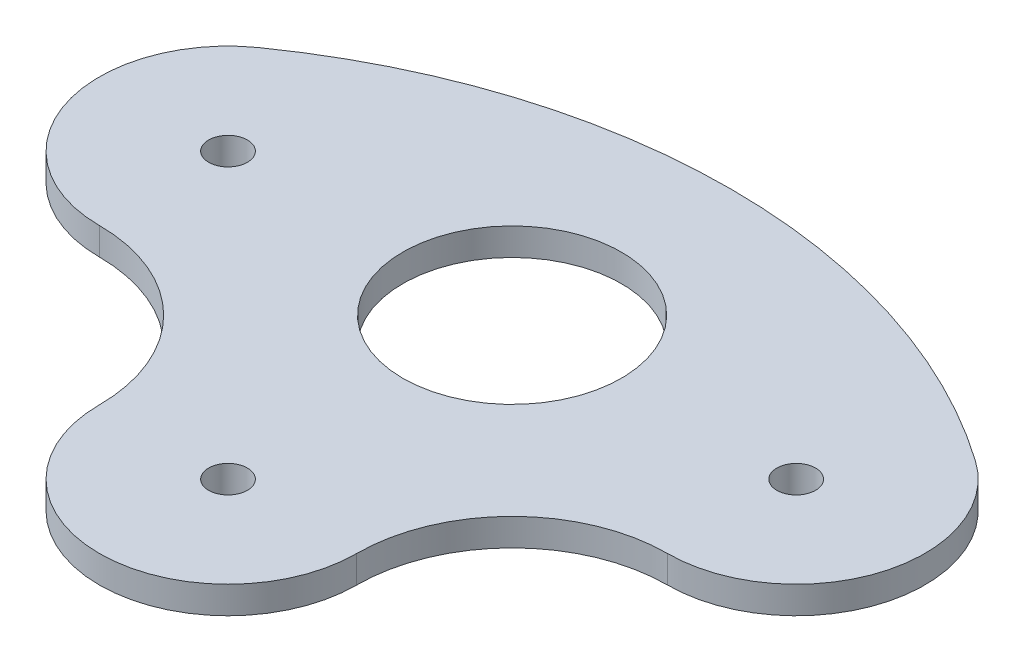
from build123d import *

# Parameters (mm, degrees)
SKETCH1_R           = 12.7
SKETCH1_R_2         = 2.25
BOSS_EXTRUDE1_DEPTH = 3.175


with BuildPart() as part:
    # Sketch1 → Boss-Extrude1 (new body)
    with BuildSketch(Plane(origin=(0, 0, 0), x_dir=(1, 0, 0), z_dir=(0, 1, 0))):
        with BuildLine():
            ThreePointArc((-41.605402676, 12.224955819), (-47.252466269, -4.513280985), (-33, -14.95))
            ThreePointArc((-33, -14.95), (-20.2367226, -20.2367226), (-14.95, -33))
            ThreePointArc((-14.95, -33), (0, -47.95), (14.95, -33))
            ThreePointArc((14.95, -33), (20.2367226, -20.2367226), (33, -14.95))
            ThreePointArc((33, -14.95), (47.252466269, -4.513280985), (41.605402676, 12.224955819))
            ThreePointArc((41.605402676, 12.224955819), (0, 25.4), (-41.605402676, 12.224955819))
        make_face()
        Circle(SKETCH1_R, mode=Mode.SUBTRACT)
        with Locations((-33, 0)):
            Circle(SKETCH1_R_2, mode=Mode.SUBTRACT)
        with Locations((33, 0)):
            Circle(SKETCH1_R_2, mode=Mode.SUBTRACT)
        with Locations((0, -33)):
            Circle(SKETCH1_R_2, mode=Mode.SUBTRACT)
    extrude(amount=BOSS_EXTRUDE1_DEPTH)


solid = part.part
